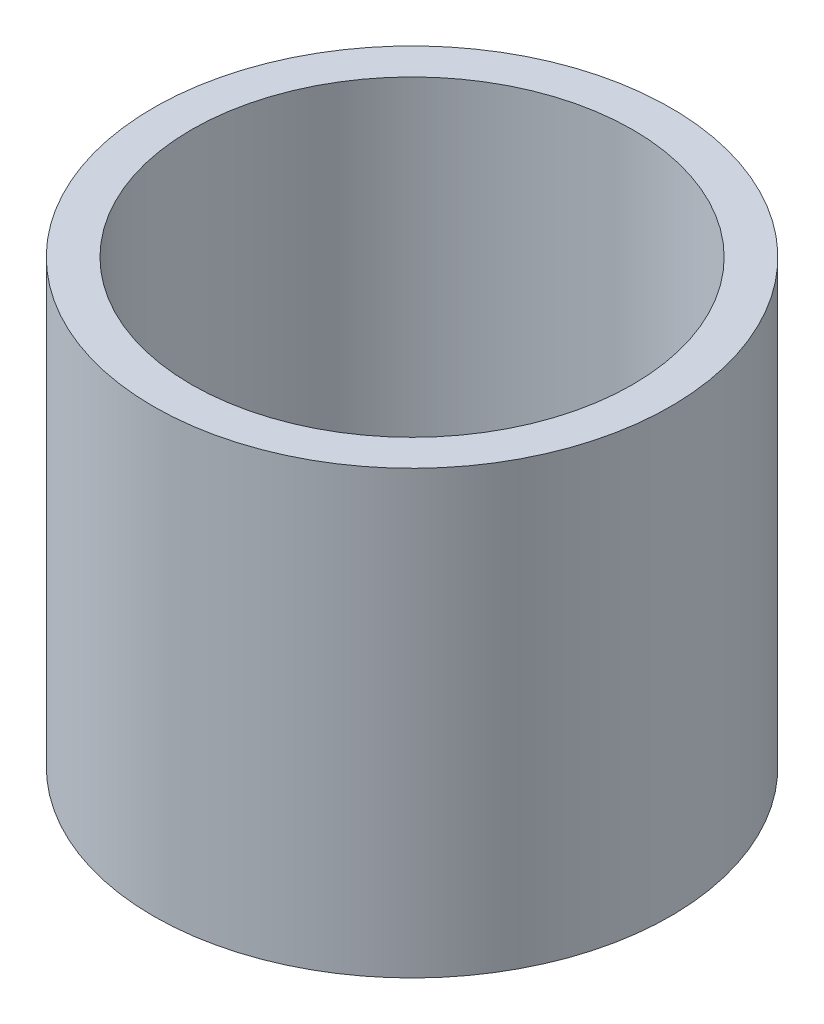
from build123d import *

# Parameters (mm, degrees)
SKETCH1_W = 1.0922
SKETCH1_H = 12.7


with BuildPart() as part:
    # Sketch1 → Revolve1 (revolve)
    with BuildSketch(Plane.XY):
        with Locations((-6.8961, -6.35)):
            Rectangle(SKETCH1_W, SKETCH1_H)
    revolve(axis=Axis((0, 0, 0), (0, -1, 0)))


solid = part.part
